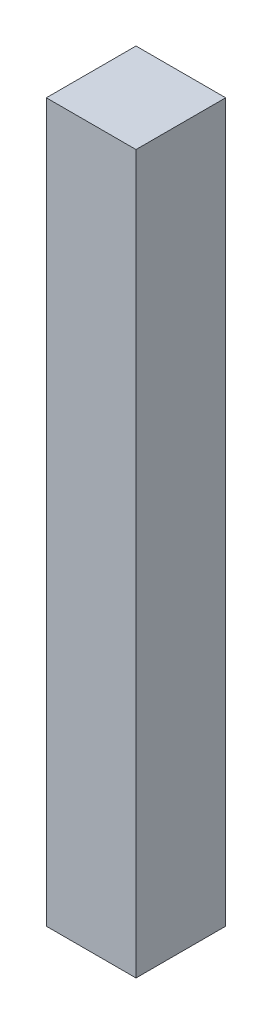
from build123d import *

# Parameters (mm, degrees)
SKETCH2_W           = 3.175
SKETCH2_H           = 25.40508
BOSS_EXTRUDE1_DEPTH = 3.175


with BuildPart() as part:
    # Sketch2 → Boss-Extrude1 (new body)
    with BuildSketch(Plane.XY):
        Rectangle(SKETCH2_W, SKETCH2_H)
    extrude(amount=BOSS_EXTRUDE1_DEPTH)


solid = part.part
